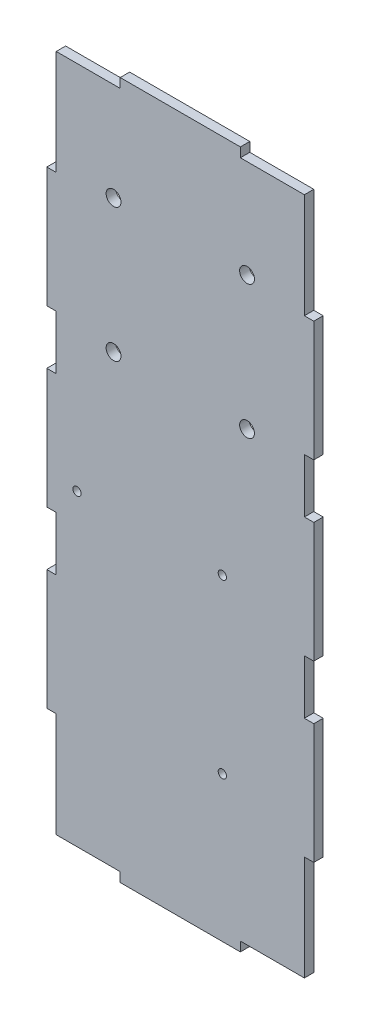
from build123d import *

# Parameters (mm, degrees)
SKETCH1_W           = 90
SKETCH1_H           = 235
SKETCH1_W_2         = 38
SKETCH1_H_2         = 49.5
SKETCH1_W_3         = 17
SKETCH1_H_3         = 26
SKETCH1_W_4         = 0.938488567
SKETCH1_R           = 1.4
SKETCH1_W_5         = 23.15
SKETCH1_H_4         = 81
SKETCH1_W_6         = 27.85
SKETCH1_W_7         = 35.5
SKETCH1_H_5         = 15
BOSS_EXTRUDE2_DEPTH = 3.175
SKETCH4_W           = 3.175
SKETCH4_H           = 18.25
CUT_EXTRUDE2_DEPTH  = 3.175
CUT_EXTRUDE3_DEPTH  = 4.175


with BuildPart() as part:
    # Sketch1 → Boss-Extrude2 (new body)
    with BuildSketch(Plane.XY):
        Rectangle(SKETCH1_W, SKETCH1_H)
        Polygon((-4.325, -114.325), (-39.825, -114.325), (-39.825, -99.325), (-41.825, -99.325), (-41.825, -96.15), (41.825, -96.15), (41.825, -99.325), (39.825, -99.325), (39.825, -114.325), (4.325, -114.325), (4.325, -99.325), (-4.325, -99.325), align=None, mode=Mode.SUBTRACT)
        Polygon((17.675, -94.15), (-10.175, -94.15), (-40.825, -94.15), (-40.825, -7.05), (17.675, -7.05), (17.675, -13.15), (40.825, -13.15), (40.825, -94.15), align=None, mode=Mode.SUBTRACT)
        with Locations((-22.825, 82.5)):
            Rectangle(SKETCH1_W_2, SKETCH1_H_2, mode=Mode.SUBTRACT)
        Polygon((23.761826634, 14.5), (6.761826634, 14.5), (6.761826634, 40.5), (23.761826634, 40.5), (24.700315201, 40.5), (41.700315201, 40.5), (41.700315201, 14.5), (24.700315201, 14.5), align=None, mode=Mode.SUBTRACT)
        with Locations((22.825, 82.5)):
            Rectangle(SKETCH1_W_2, SKETCH1_H_2, mode=Mode.SUBTRACT)
        with Locations((-22.825, 82.5)):
            Rectangle(SKETCH1_W_2, SKETCH1_H_2)
        with Locations((22.825, 82.5)):
            Rectangle(SKETCH1_W_2, SKETCH1_H_2)
        with Locations((33.200315201, 27.5)):
            Rectangle(SKETCH1_W_3, SKETCH1_H_3)
        with Locations((15.261826634, 27.5)):
            Rectangle(SKETCH1_W_3, SKETCH1_H_3)
        with Locations((24.231070918, 27.5)):
            Rectangle(SKETCH1_W_4, SKETCH1_H_3)
        Polygon((-40.825, -94.15), (-10.175, -94.15), (-10.175, -13.15), (17.675, -13.15), (17.675, -7.05), (-40.825, -7.05), align=None)
        with Locations((-34.825, -10.55)):
            Circle(SKETCH1_R, mode=Mode.SUBTRACT)
        with Locations((14.175, -10.55)):
            Circle(SKETCH1_R, mode=Mode.SUBTRACT)
        with Locations((29.25, -53.65)):
            Rectangle(SKETCH1_W_5, SKETCH1_H_4)
        with Locations((37.325, -90.65)):
            Circle(SKETCH1_R, mode=Mode.SUBTRACT)
        with Locations((37.325, -19.53)):
            Circle(SKETCH1_R, mode=Mode.SUBTRACT)
        with Locations((3.75, -53.65)):
            Rectangle(SKETCH1_W_6, SKETCH1_H_4)
        with Locations((14.175, -68.55)):
            Circle(SKETCH1_R, mode=Mode.SUBTRACT)
        with Locations((-22.075, -106.825)):
            Rectangle(SKETCH1_W_7, SKETCH1_H_5)
        with Locations((22.075, -106.825)):
            Rectangle(SKETCH1_W_7, SKETCH1_H_5)
        Polygon((-41.825, -99.325), (-39.825, -99.325), (-4.325, -99.325), (4.325, -99.325), (39.825, -99.325), (41.825, -99.325), (41.825, -96.15), (-41.825, -96.15), align=None)
        with Locations((37.325, -19.53)):
            Circle(SKETCH1_R)
        with Locations((37.325, -90.65)):
            Circle(SKETCH1_R)
    extrude(amount=BOSS_EXTRUDE2_DEPTH)

    # Sketch4 → Cut-Extrude2 (cut)
    with BuildSketch(Plane.XY.offset(3.175)):
        Polygon((-41.825, 114.325), (-20.25, 114.325), (-20.25, 117.5), (-45, 117.5), (-45, 79), (-41.825, 79), align=None)
        Polygon((41.825, 114.325), (41.825, 79), (45, 79), (45, 117.5), (20.25, 117.5), (20.25, 114.325), align=None)
        with Locations((-43.4125, 29.375)):
            Rectangle(SKETCH4_W, SKETCH4_H)
        with Locations((-43.4125, -29.375)):
            Rectangle(SKETCH4_W, SKETCH4_H)
        Polygon((-20.25, -117.5), (-20.25, -114.325), (-41.825, -114.325), (-41.825, -79), (-45, -79), (-45, -117.5), align=None)
        Polygon((45, -79), (41.825, -79), (41.825, -114.325), (20.25, -114.325), (20.25, -117.5), (45, -117.5), align=None)
        with Locations((43.4125, -29.375)):
            Rectangle(SKETCH4_W, SKETCH4_H)
        with Locations((43.4125, 29.375)):
            Rectangle(SKETCH4_W, SKETCH4_H)
    extrude(amount=-CUT_EXTRUDE2_DEPTH, mode=Mode.SUBTRACT)

    # Sketch5 → Cut-Extrude3 (cut, through all)
    with BuildSketch(Plane(origin=(0, 0, 0), x_dir=(-1, 0, 0), z_dir=(0, 0, -1))):
        with BuildLine():
            Line((-22.5, 38.75), (-22.5, 36.25))
            Line((-22.5, 36.25), (-20, 36.25))
            ThreePointArc((-20, 36.25), (-20.732233047, 38.017766953), (-22.5, 38.75))
        make_face()
        with BuildLine():
            Line((-20, 36.25), (-22.5, 36.25))
            Line((-22.5, 36.25), (-22.5, 38.75))
            ThreePointArc((-22.5, 38.75), (-24.267766953, 34.482233047), (-20, 36.25))
        make_face()
        with BuildLine():
            ThreePointArc((22.5, 38.75), (20.732233047, 38.017766953), (20, 36.25))
            Line((20, 36.25), (22.5, 36.25))
            Line((22.5, 36.25), (22.5, 38.75))
        make_face()
        with BuildLine():
            Line((22.5, 36.25), (20, 36.25))
            ThreePointArc((20, 36.25), (22.5, 33.75), (25, 36.25))
            ThreePointArc((25, 36.25), (24.267766953, 38.017766953), (22.5, 38.75))
            Line((22.5, 38.75), (22.5, 36.25))
        make_face()
        with BuildLine():
            ThreePointArc((20, 81.25), (20.732233047, 79.482233047), (22.5, 78.75))
            Line((22.5, 78.75), (22.5, 81.25))
            Line((22.5, 81.25), (20, 81.25))
        make_face()
        with BuildLine():
            Line((22.5, 81.25), (22.5, 78.75))
            ThreePointArc((22.5, 78.75), (24.267766953, 79.482233047), (25, 81.25))
            ThreePointArc((25, 81.25), (22.5, 83.75), (20, 81.25))
            Line((20, 81.25), (22.5, 81.25))
        make_face()
        with BuildLine():
            ThreePointArc((-20, 81.25), (-24.267766953, 83.017766953), (-22.5, 78.75))
            Line((-22.5, 78.75), (-22.5, 81.25))
            Line((-22.5, 81.25), (-20, 81.25))
        make_face()
        with BuildLine():
            Line((-22.5, 81.25), (-22.5, 78.75))
            ThreePointArc((-22.5, 78.75), (-20.732233047, 79.482233047), (-20, 81.25))
            Line((-20, 81.25), (-22.5, 81.25))
        make_face()
    extrude(amount=-CUT_EXTRUDE3_DEPTH, mode=Mode.SUBTRACT)


solid = part.part
